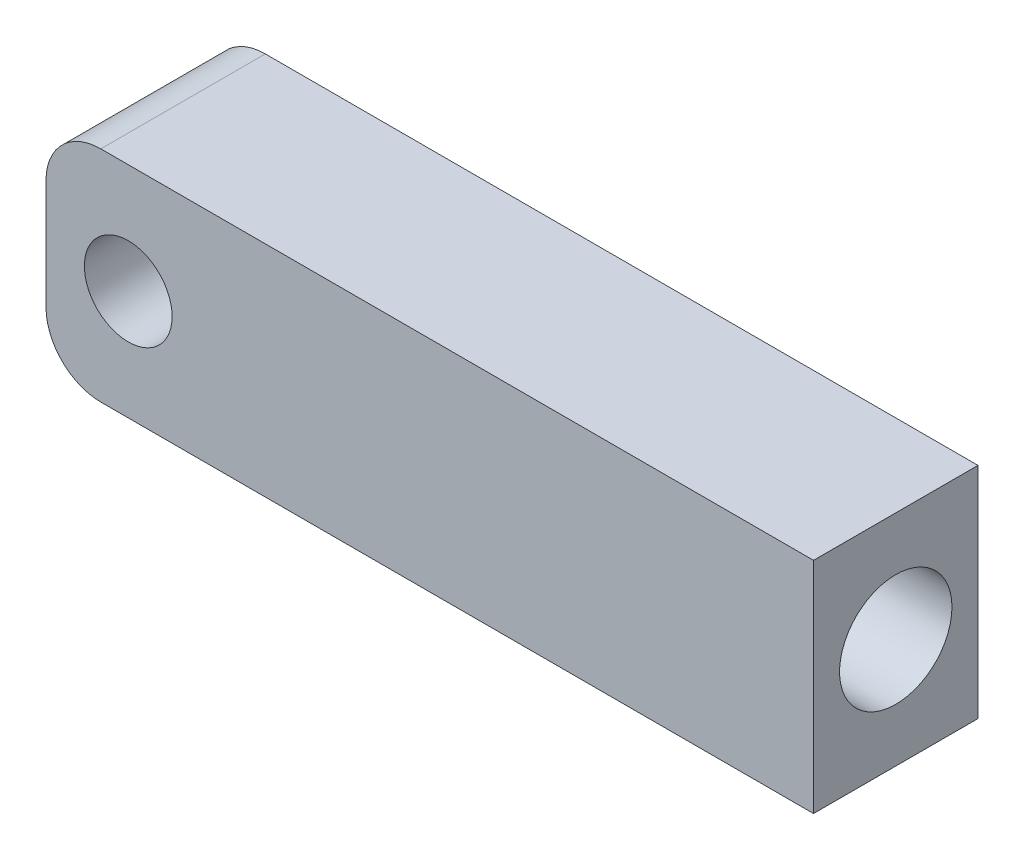
from build123d import *

# Parameters (mm, degrees)
SKETCH_2_R          = 1.6
EXTRUDE_1_DEPTH     = 6
SKETCH_3_R          = 2.05
CUT_EXTRUDE_1_DEPTH = 20


with BuildPart() as part:
    # 草图2 → 凸台-拉伸1 (new body)
    with BuildSketch(Plane.XY):
        with BuildLine():
            Line((0, 2), (0, 6))
            ThreePointArc((0, 6), (0.585786438, 7.414213562), (2, 8))
            Line((2, 8), (28, 8))
            Line((28, 8), (28, 0))
            Line((28, 0), (2, 0))
            ThreePointArc((2, 0), (0.585786438, 0.585786438), (0, 2))
        make_face()
        with Locations((3, 4)):
            Circle(SKETCH_2_R, mode=Mode.SUBTRACT)
    extrude(amount=EXTRUDE_1_DEPTH)

    # 草图3 → 切除-拉伸1 (cut)
    with BuildSketch(Plane(origin=(28, 0, 0), x_dir=(0, 0, -1), z_dir=(1, 0, 0))):
        with Locations((-3, 4)):
            Circle(SKETCH_3_R)
    extrude(amount=-CUT_EXTRUDE_1_DEPTH, mode=Mode.SUBTRACT)


solid = part.part
